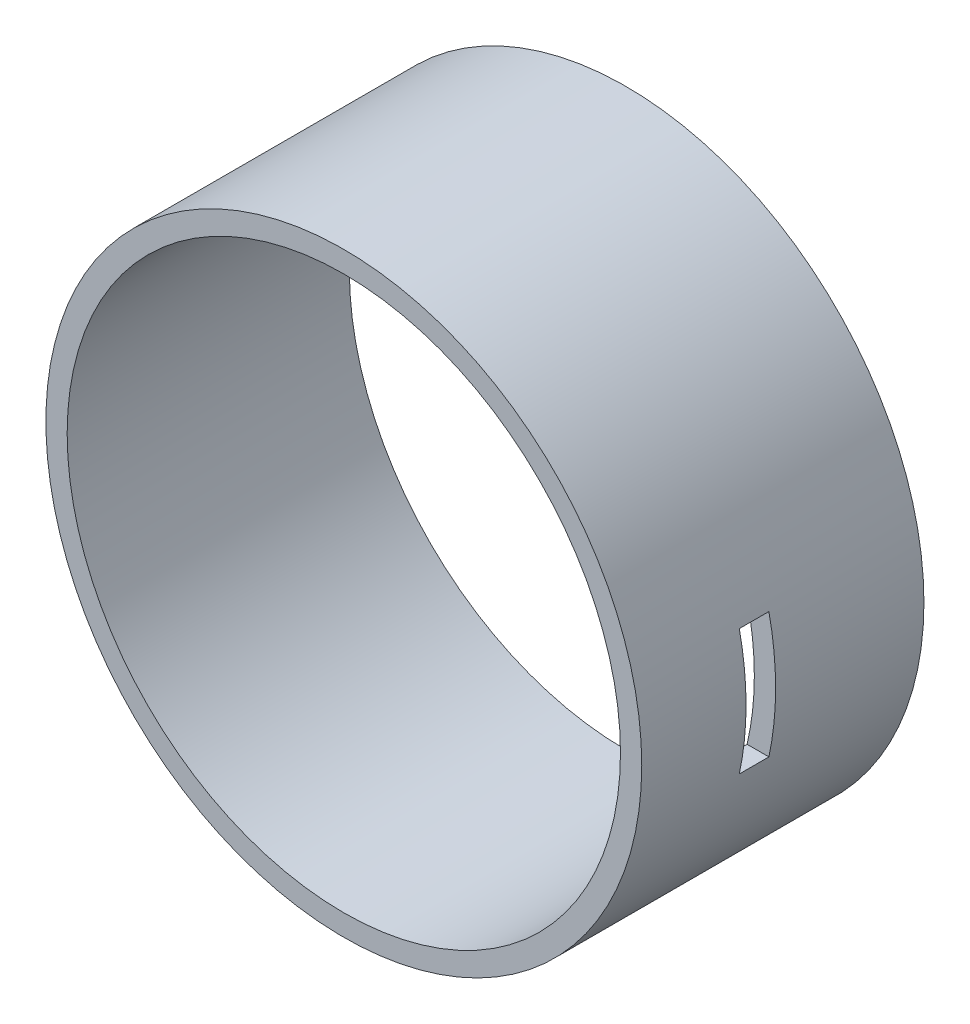
from build123d import *

# Parameters (mm, degrees)
SKETCH1_R                 = 140
SKETCH1_R_2               = 130
BOSS_EXTRUDE1_DEPTH       = 132.6
M4X0_7_TAPPED_HOLE1_D     = 3.3
M4X0_7_TAPPED_HOLE1_DEPTH = 20
M4X0_7_TAPPED_HOLE1_TIP   = 0.991420021
SKETCH5_W                 = 13.9
SKETCH5_H                 = 59.15
CUT_EXTRUDE1_DEPTH        = 140


with BuildPart() as part:
    # Sketch1 → Boss-Extrude1 (new body)
    with BuildSketch(Plane.XY):
        Circle(SKETCH1_R)
        Circle(SKETCH1_R_2, mode=Mode.SUBTRACT)
    extrude(amount=BOSS_EXTRUDE1_DEPTH)

    # M4x0.7 Tapped Hole1
    with Locations(Plane(origin=(0, 0, 0), x_dir=(-1, 0, 0), z_dir=(0, 0, -1))):
        with Locations((0, 135), (135, 0), (95.5, 95.5), (95.5, -95.5), (0, -135), (-95.5, -95.5), (-135, 0), (-95.5, 95.5)):
            Hole(M4X0_7_TAPPED_HOLE1_D / 2, depth=M4X0_7_TAPPED_HOLE1_DEPTH)
            with Locations((0, 0, -(M4X0_7_TAPPED_HOLE1_DEPTH + M4X0_7_TAPPED_HOLE1_TIP / 2))):  # 118° drill point
                Cone(0, M4X0_7_TAPPED_HOLE1_D / 2, M4X0_7_TAPPED_HOLE1_TIP, mode=Mode.SUBTRACT)

    # Sketch5 → Cut-Extrude1 (cut)
    with BuildSketch(Plane(origin=(0, 0, 0), x_dir=(0, 0, -1), z_dir=(1, 0, 0))):
        with Locations((-76.65, 0)):
            Rectangle(SKETCH5_W, SKETCH5_H)
    extrude(amount=CUT_EXTRUDE1_DEPTH, mode=Mode.SUBTRACT)


solid = part.part
